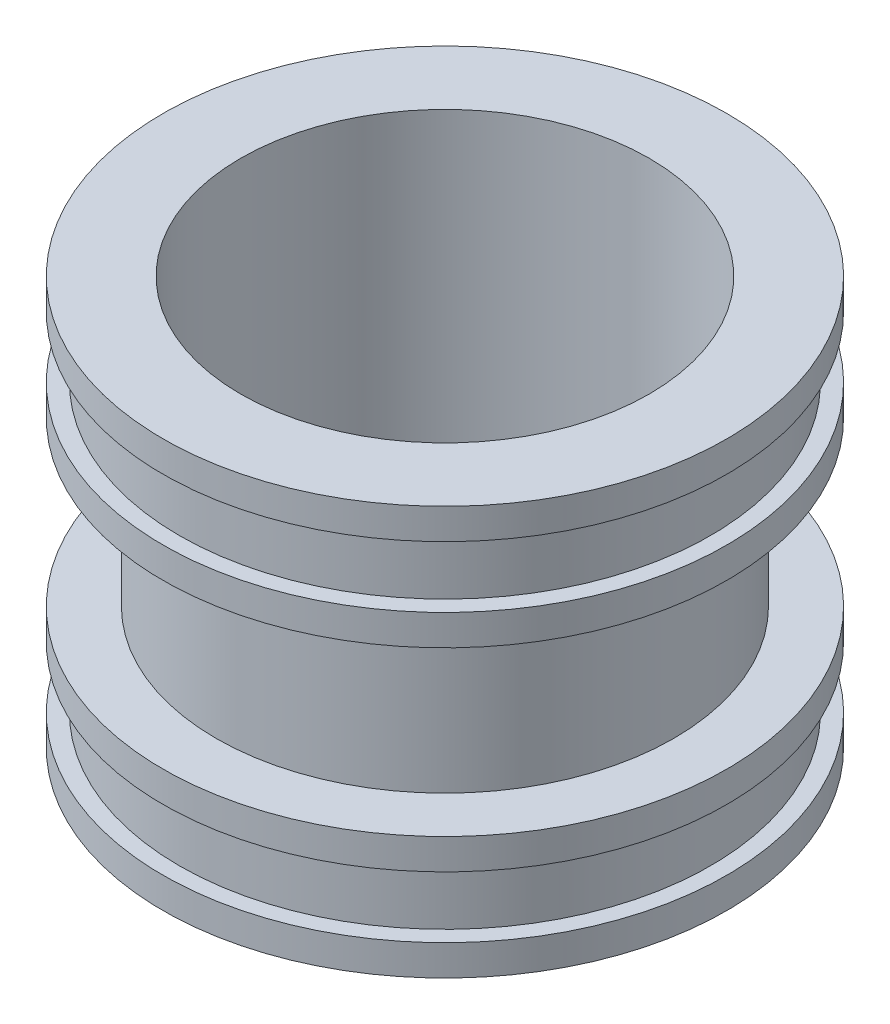
from build123d import *


with BuildPart() as part:
    # Esboço1 → Revolução1 (revolve)
    with BuildSketch(Plane.XY):
        Polygon((50, 100), (69, 100), (69, 92.5), (65, 92.5), (65, 77.5), (69, 77.5), (69, 70), (56, 70), (56, 30), (69, 30), (69, 22.5), (65, 22.5), (65, 7.5), (69, 7.5), (69, 0), (50, 0), align=None)
    revolve(axis=Axis((0, 0, 0), (0, 1, 0)))


solid = part.part
